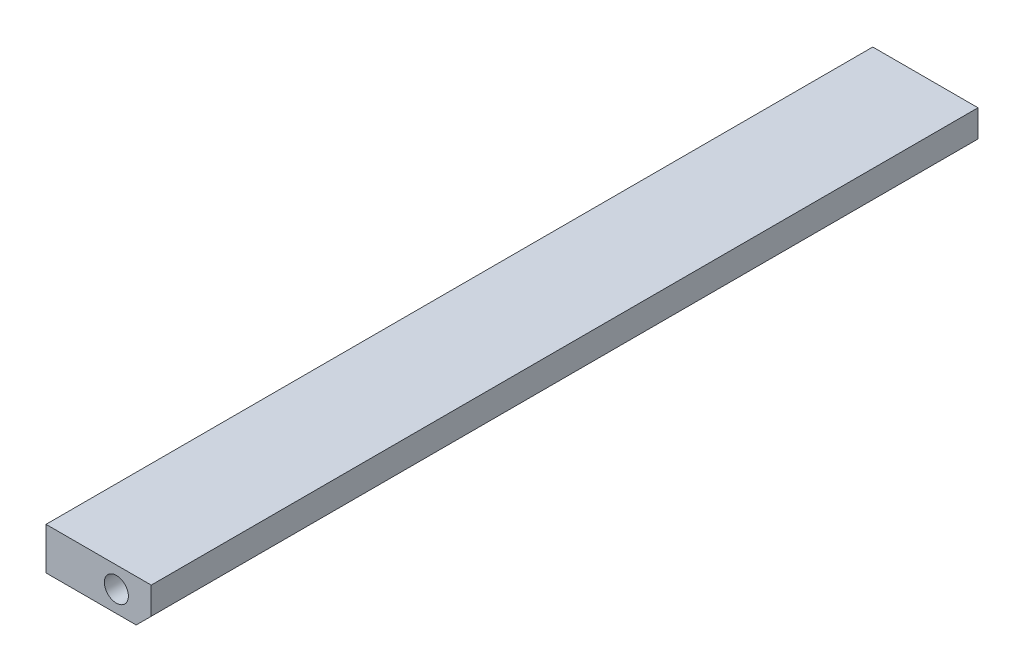
from build123d import *

# Parameters (mm, degrees)
SKETCH_1_W          = 35
SKETCH_1_H          = 14
EXTRUDE_1_DEPTH     = 275
CHAMFER_1_SIZE      = 5
SKETCH_2_R          = 4
CUT_EXTRUDE_1_DEPTH = 10


with BuildPart() as part:
    # 草图1 → 凸台-拉伸1 (new body)
    with BuildSketch(Plane.XY):
        Rectangle(SKETCH_1_W, SKETCH_1_H)
    extrude(amount=EXTRUDE_1_DEPTH)

    # 倒角1
    chamfer_1_edges = [part.edges().sort_by_distance(p)[0] for p in [
        (17.5, -7, 137.5),
    ]]
    chamfer(chamfer_1_edges, length=CHAMFER_1_SIZE)

    # 草图2 → 切除-拉伸1 (cut)
    with BuildSketch(Plane.XY.offset(275)):
        with Locations((5.9, 0)):
            Circle(SKETCH_2_R)
    cut_extrude_1 = extrude(amount=-CUT_EXTRUDE_1_DEPTH, mode=Mode.SUBTRACT)

    # 镜向1: 切除-拉伸1 across plane
    add(cut_extrude_1.mirror(Plane(origin=(0, 0, 137.5), x_dir=(1, 0, 0), z_dir=(0, 0, -1))), mode=Mode.SUBTRACT)


solid = part.part
